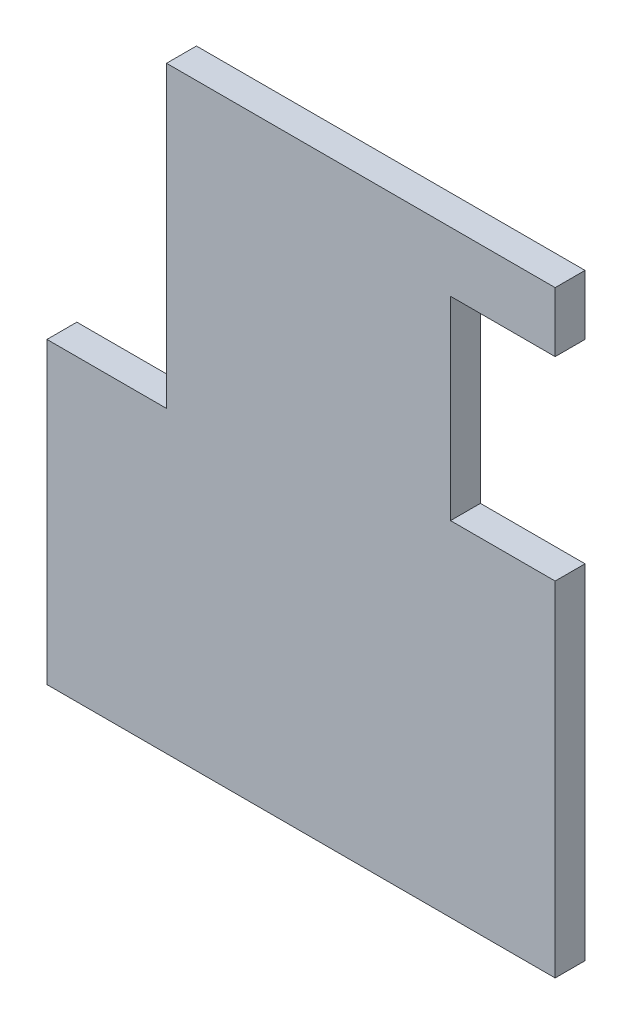
from build123d import *

# Parameters (mm, degrees)
BOSS_EXTRUDE1_DEPTH = 10


with BuildPart() as part:
    # Sketch2 → Boss-Extrude1 (new body)
    with BuildSketch(Plane.XY):
        Polygon((-89.092751524, -29.442704268), (80.907248476, -29.442704268), (80.907248476, 85.557295732), (45.907248476, 85.557295732), (45.907248476, 150.557295732), (80.907248476, 150.557295732), (80.907248476, 170.557295732), (-49.092751524, 170.557295732), (-49.092751524, 70.557295732), (-89.092751524, 70.557295732), align=None)
    extrude(amount=BOSS_EXTRUDE1_DEPTH)


solid = part.part
